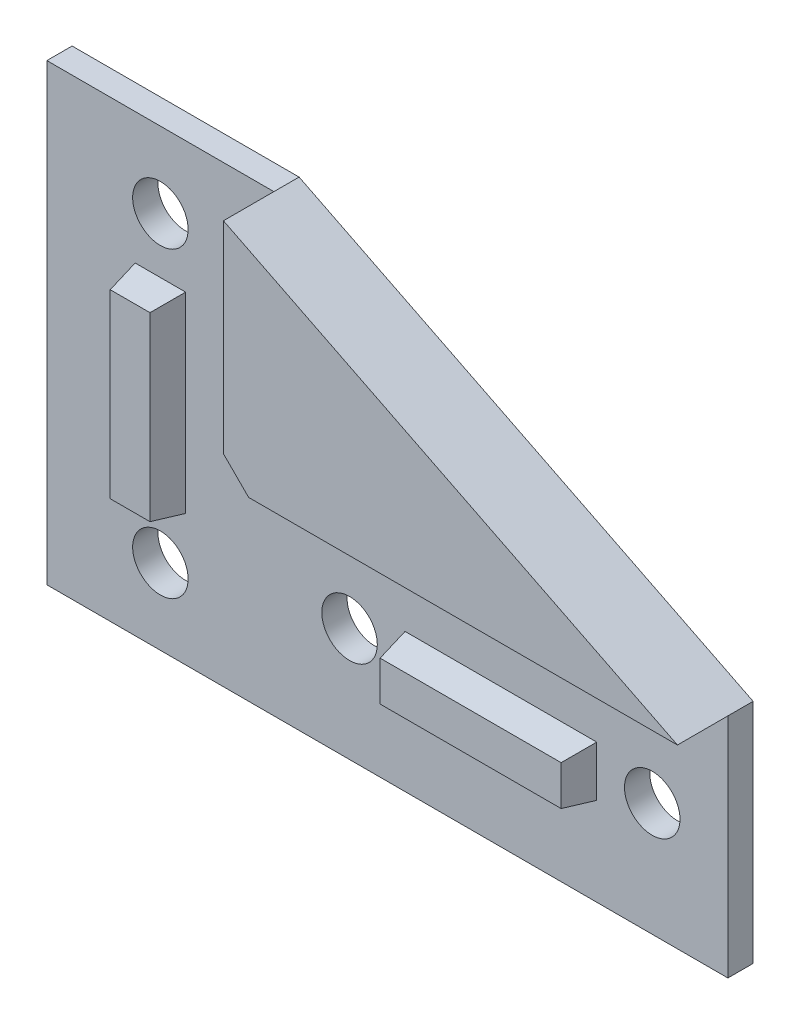
from build123d import *

# Parameters (mm, degrees)
ESQUISSE1_R        = 5.5
BOSS_EXTRU_1_DEPTH = 5
ESQUISSE2_W        = 10
ESQUISSE2_H        = 38
ESQUISSE2_W_2      = 38
ESQUISSE2_H_2      = 10
BOSS_EXTRU_2_DEPTH = 6
D_POUILLE3_ANGLE   = 10
BOSS_EXTRU_3_DEPTH = 10
CHANFREIN1_SIZE    = 5


with BuildPart() as part:
    # Esquisse1 → Boss.-Extru.1 (new body)
    with BuildSketch(Plane.XY):
        Polygon((0, 0), (0, 90), (45, 90), (135, 45), (135, 0), align=None)
        with Locations((22.5, 75)):
            Circle(ESQUISSE1_R, mode=Mode.SUBTRACT)
        with Locations((22.5, 15)):
            Circle(ESQUISSE1_R, mode=Mode.SUBTRACT)
        with Locations((120, 22.5)):
            Circle(ESQUISSE1_R, mode=Mode.SUBTRACT)
        with Locations((60, 22.5)):
            Circle(ESQUISSE1_R, mode=Mode.SUBTRACT)
    extrude(amount=BOSS_EXTRU_1_DEPTH)

    # Esquisse2 → Boss.-Extru.2 (add)
    with BuildSketch(Plane.XY.offset(5)):
        with Locations((22.5, 45)):
            Rectangle(ESQUISSE2_W, ESQUISSE2_H)
        with Locations((90, 22.5)):
            Rectangle(ESQUISSE2_W_2, ESQUISSE2_H_2)
    extrude(amount=BOSS_EXTRU_2_DEPTH)

    # Dépouille3
    d_pouille3_faces = [part.faces().sort_by_distance(p)[0] for p in [
        (90, 27.5, 8),
        (109, 22.5, 8),
        (71, 22.5, 8),
        (90, 17.5, 8),
        (22.5, 26, 8),
        (27.5, 45, 8),
        (22.5, 64, 8),
        (17.5, 45, 8),
    ]]
    draft(d_pouille3_faces, Plane.XY.offset(5), D_POUILLE3_ANGLE)

    # Esquisse3 → Boss.-Extru.3 (add)
    with BuildSketch(Plane.XY.offset(5)):
        Polygon((45, 90), (45, 45), (135, 45), align=None)
    extrude(amount=BOSS_EXTRU_3_DEPTH)

    # Chanfrein1
    chanfrein1_edges = [part.edges().sort_by_distance(p)[0] for p in [
        (45, 45, 10),
    ]]
    chamfer(chanfrein1_edges, length=CHANFREIN1_SIZE)


solid = part.part
